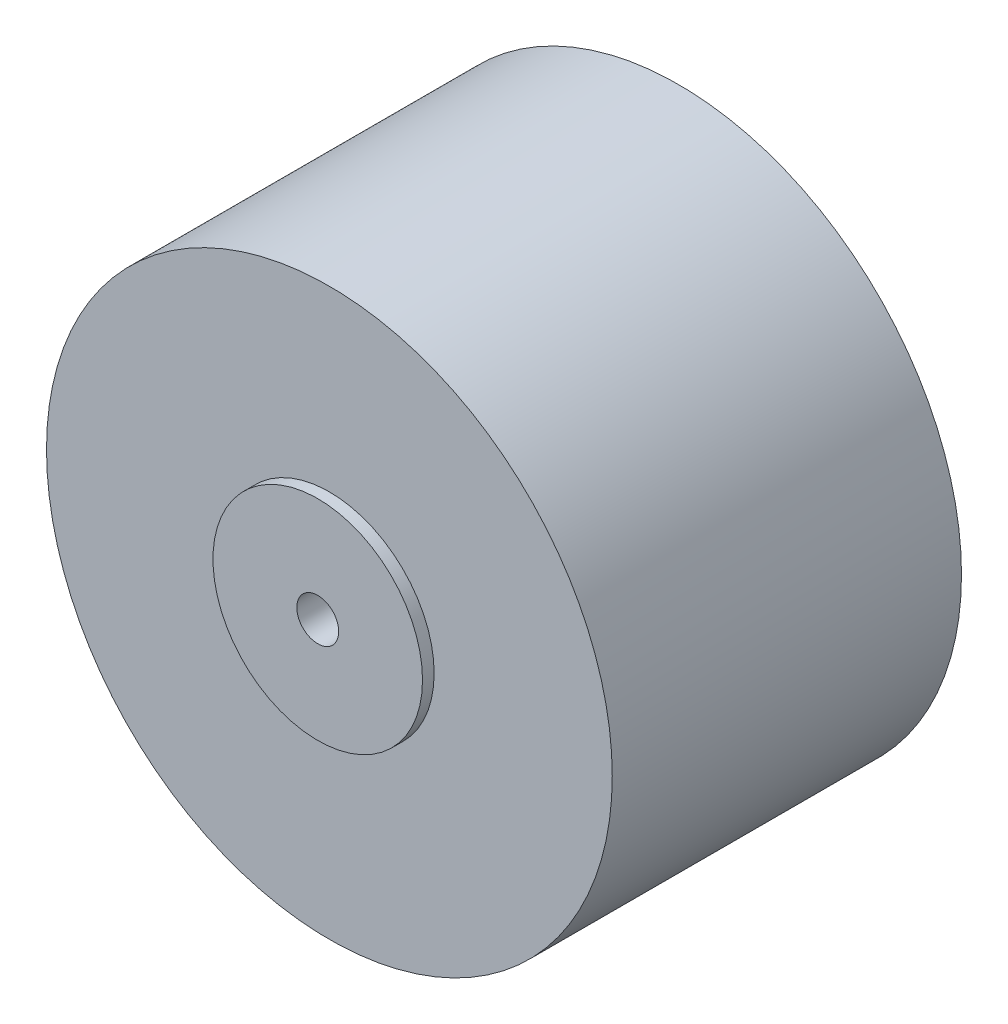
from build123d import *

# Parameters (mm, degrees)
ESBO_O1_R                  = 12.15
RESSALTO_EXTRUS_O1_DEPTH   = 15
ESBO_O2_R                  = 4.5
RESSALTO_EXTRUS_O2_DEPTH   = 15.5
ESBO_O3_R                  = 0.9
CORTE_EXTRUS_O1_DEPTH      = 19.5
CORTE_EXTRUS_O1_DEPTH_BACK = 15.5


with BuildPart() as part:
    # Esboço1 → Ressalto-extrusão1 (new body)
    with BuildSketch(Plane.XY):
        Circle(ESBO_O1_R)
    extrude(amount=RESSALTO_EXTRUS_O1_DEPTH)

    # Esboço2 → Ressalto-extrusão2 (add)
    with BuildSketch(Plane.XY):
        Circle(ESBO_O2_R)
    extrude(amount=RESSALTO_EXTRUS_O2_DEPTH)

    # Esboço3 → Corte-extrusão1 (cut, two sides)
    with BuildSketch(Plane.XY) as corte_extrus_o1_sk:
        Circle(ESBO_O3_R)
    extrude(amount=CORTE_EXTRUS_O1_DEPTH, mode=Mode.SUBTRACT)
    extrude(corte_extrus_o1_sk.sketch, amount=-CORTE_EXTRUS_O1_DEPTH_BACK, mode=Mode.SUBTRACT)


solid = part.part
